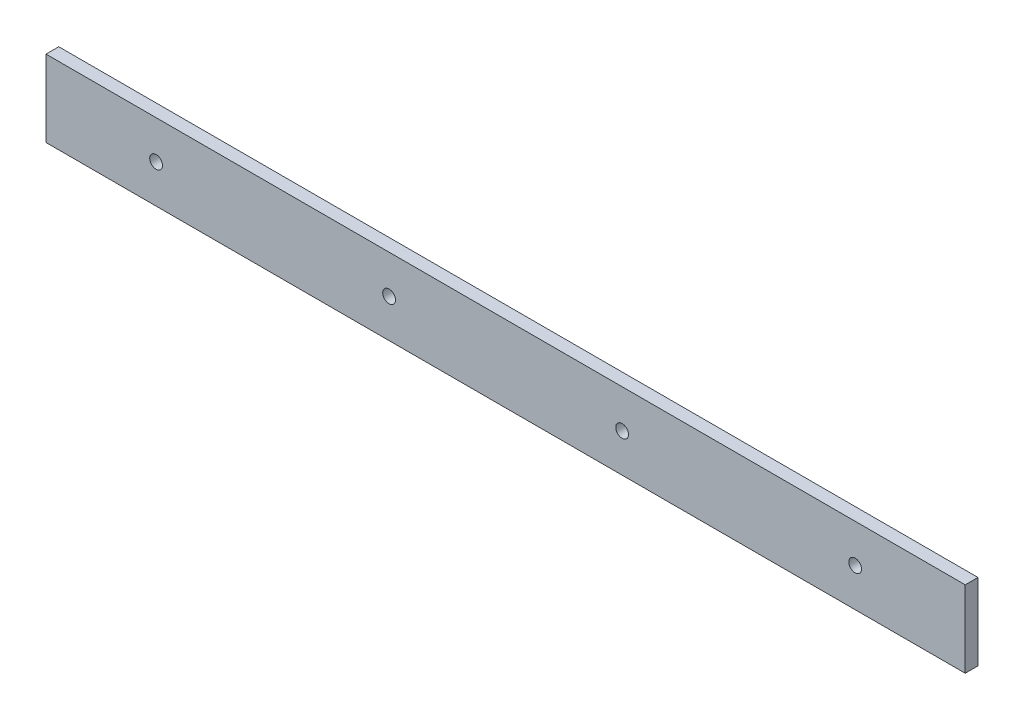
from build123d import *

# Parameters (mm, degrees)
SKETCH1_W           = 457.2
SKETCH1_H           = 38.1
SKETCH1_R           = 3.175
BOSS_EXTRUDE1_DEPTH = 6.35


with BuildPart() as part:
    # Sketch1 → Boss-Extrude1 (new body)
    with BuildSketch(Plane.XY):
        with Locations((228.6, 19.05)):
            Rectangle(SKETCH1_W, SKETCH1_H)
        with Locations((54.7497, 19.05)):
            Circle(SKETCH1_R, mode=Mode.SUBTRACT)
        with Locations((170.6499, 19.05)):
            Circle(SKETCH1_R, mode=Mode.SUBTRACT)
        with Locations((286.5501, 19.05)):
            Circle(SKETCH1_R, mode=Mode.SUBTRACT)
        with Locations((402.4503, 19.05)):
            Circle(SKETCH1_R, mode=Mode.SUBTRACT)
    extrude(amount=BOSS_EXTRUDE1_DEPTH)


solid = part.part
